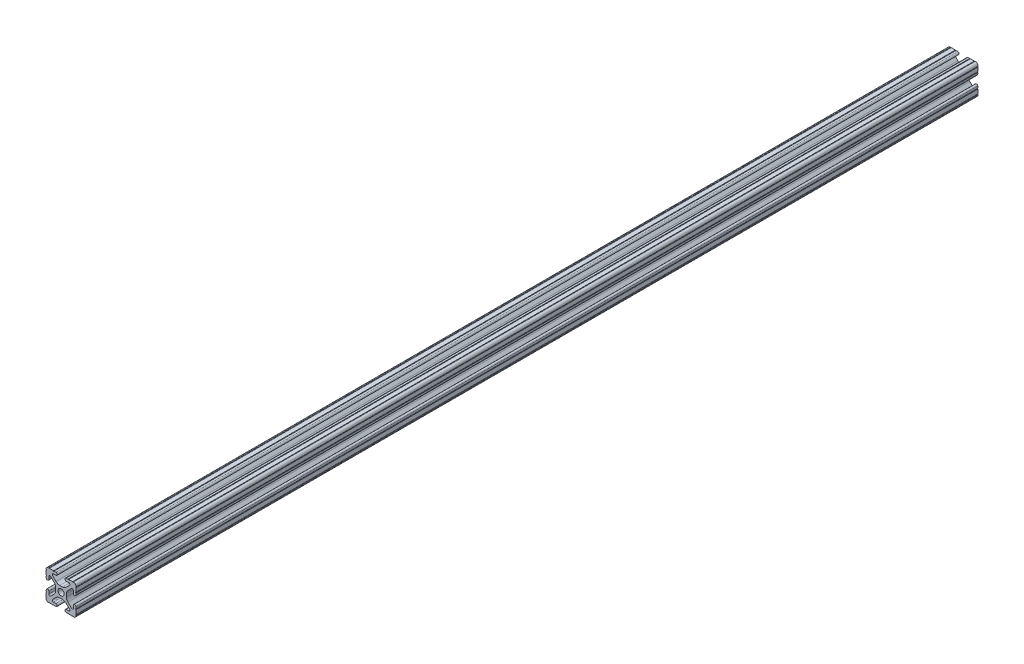
from build123d import *

# Parameters (mm, degrees)
SKETCH3_R      = 2.6035
EXTRUDE1_DEPTH = 380


with BuildPart() as part:
    # Sketch3 → Extrude1 (new body, symmetric)
    with BuildSketch(Plane.XY):
        with BuildLine():
            Line((-1.115277175, 4.5085), (1.115277175, 4.5085))
            ThreePointArc((1.115277175, 4.5085), (2.806584872, 4.844922018), (4.240406305, 5.80297087))
            Line((4.240406305, 5.80297087), (7.148423664, 8.710988229))
            ThreePointArc((7.148423664, 8.710988229), (7.349906316, 9.772227925), (6.436353897, 10.348636575))
            Line((6.436353897, 10.348636575), (4.381960454, 10.276895575))
            ThreePointArc((4.381960454, 10.276895575), (3.239173075, 11.342562046), (4.304839546, 12.485349424))
            Line((4.304839546, 12.485349424), (5.728246175, 12.535055879))
            ThreePointArc((5.728246175, 12.535055879), (6.054756855, 12.230579745), (6.35923299, 12.557090424))
            Line((6.35923299, 12.557090424), (9.782092278, 12.676619304))
            ThreePointArc((9.782092278, 12.676619304), (10.108602958, 12.37214317), (10.413079092, 12.69865385))
            ThreePointArc((10.413079092, 12.69865385), (12.052764565, 12.052764565), (12.69865385, 10.413079092))
            ThreePointArc((12.69865385, 10.413079092), (12.37214317, 10.108602958), (12.676619304, 9.782092278))
            Line((12.676619304, 9.782092278), (12.557090424, 6.35923299))
            ThreePointArc((12.557090424, 6.35923299), (12.230579745, 6.054756855), (12.535055879, 5.728246175))
            Line((12.535055879, 5.728246175), (12.485349424, 4.304839546))
            ThreePointArc((12.485349424, 4.304839546), (11.342562046, 3.239173075), (10.276895575, 4.381960454))
            Line((10.276895575, 4.381960454), (10.348636575, 6.436353897))
            ThreePointArc((10.348636575, 6.436353897), (9.772227925, 7.349906316), (8.710988229, 7.148423664))
            Line((8.710988229, 7.148423664), (5.80297087, 4.240406305))
            ThreePointArc((5.80297087, 4.240406305), (4.844922018, 2.806584872), (4.5085, 1.115277175))
            Line((4.5085, 1.115277175), (4.5085, -1.115277175))
            ThreePointArc((4.5085, -1.115277175), (4.844922018, -2.806584872), (5.80297087, -4.240406305))
            Line((5.80297087, -4.240406305), (8.710988229, -7.148423664))
            ThreePointArc((8.710988229, -7.148423664), (9.772227925, -7.349906316), (10.348636575, -6.436353897))
            Line((10.348636575, -6.436353897), (10.276895575, -4.381960454))
            ThreePointArc((10.276895575, -4.381960454), (11.342562046, -3.239173075), (12.485349424, -4.304839546))
            Line((12.485349424, -4.304839546), (12.535055879, -5.728246175))
            ThreePointArc((12.535055879, -5.728246175), (12.230579745, -6.054756855), (12.557090424, -6.35923299))
            Line((12.557090424, -6.35923299), (12.676619304, -9.782092278))
            ThreePointArc((12.676619304, -9.782092278), (12.37214317, -10.108602958), (12.69865385, -10.413079092))
            ThreePointArc((12.69865385, -10.413079092), (12.052764565, -12.052764565), (10.413079092, -12.69865385))
            ThreePointArc((10.413079092, -12.69865385), (10.108602958, -12.37214317), (9.782092278, -12.676619304))
            Line((9.782092278, -12.676619304), (6.35923299, -12.557090424))
            ThreePointArc((6.35923299, -12.557090424), (6.054756855, -12.230579745), (5.728246175, -12.535055879))
            Line((5.728246175, -12.535055879), (4.304839546, -12.485349424))
            ThreePointArc((4.304839546, -12.485349424), (3.239173075, -11.342562046), (4.381960454, -10.276895575))
            Line((4.381960454, -10.276895575), (6.436353897, -10.348636575))
            ThreePointArc((6.436353897, -10.348636575), (7.349906316, -9.772227925), (7.148423664, -8.710988229))
            Line((7.148423664, -8.710988229), (4.240406305, -5.80297087))
            ThreePointArc((4.240406305, -5.80297087), (2.806584872, -4.844922018), (1.115277175, -4.5085))
            Line((1.115277175, -4.5085), (-1.115277175, -4.5085))
            ThreePointArc((-1.115277175, -4.5085), (-2.806584872, -4.844922018), (-4.240406305, -5.80297087))
            Line((-4.240406305, -5.80297087), (-7.148423664, -8.710988229))
            ThreePointArc((-7.148423664, -8.710988229), (-7.349906316, -9.772227925), (-6.436353897, -10.348636575))
            Line((-6.436353897, -10.348636575), (-4.381960454, -10.276895575))
            ThreePointArc((-4.381960454, -10.276895575), (-3.239173075, -11.342562046), (-4.304839546, -12.485349424))
            Line((-4.304839546, -12.485349424), (-5.728246175, -12.535055879))
            ThreePointArc((-5.728246175, -12.535055879), (-6.054756855, -12.230579745), (-6.35923299, -12.557090424))
            Line((-6.35923299, -12.557090424), (-9.782092278, -12.676619304))
            ThreePointArc((-9.782092278, -12.676619304), (-10.108602958, -12.37214317), (-10.413079092, -12.69865385))
            ThreePointArc((-10.413079092, -12.69865385), (-12.052764565, -12.052764565), (-12.69865385, -10.413079092))
            ThreePointArc((-12.69865385, -10.413079092), (-12.37214317, -10.108602958), (-12.676619304, -9.782092278))
            Line((-12.676619304, -9.782092278), (-12.557090424, -6.35923299))
            ThreePointArc((-12.557090424, -6.35923299), (-12.230579745, -6.054756855), (-12.535055879, -5.728246175))
            Line((-12.535055879, -5.728246175), (-12.485349424, -4.304839546))
            ThreePointArc((-12.485349424, -4.304839546), (-11.342562046, -3.239173075), (-10.276895575, -4.381960454))
            Line((-10.276895575, -4.381960454), (-10.348636575, -6.436353897))
            ThreePointArc((-10.348636575, -6.436353897), (-9.772227925, -7.349906316), (-8.710988229, -7.148423664))
            Line((-8.710988229, -7.148423664), (-5.80297087, -4.240406305))
            ThreePointArc((-5.80297087, -4.240406305), (-4.844922018, -2.806584872), (-4.5085, -1.115277175))
            Line((-4.5085, -1.115277175), (-4.5085, 1.115277175))
            ThreePointArc((-4.5085, 1.115277175), (-4.844922018, 2.806584872), (-5.80297087, 4.240406305))
            Line((-5.80297087, 4.240406305), (-8.710988229, 7.148423664))
            ThreePointArc((-8.710988229, 7.148423664), (-9.772227925, 7.349906316), (-10.348636575, 6.436353897))
            Line((-10.348636575, 6.436353897), (-10.276895575, 4.381960454))
            ThreePointArc((-10.276895575, 4.381960454), (-11.342562046, 3.239173075), (-12.485349424, 4.304839546))
            Line((-12.485349424, 4.304839546), (-12.535055879, 5.728246175))
            ThreePointArc((-12.535055879, 5.728246175), (-12.230579745, 6.054756855), (-12.557090424, 6.35923299))
            Line((-12.557090424, 6.35923299), (-12.676619304, 9.782092278))
            ThreePointArc((-12.676619304, 9.782092278), (-12.37214317, 10.108602958), (-12.69865385, 10.413079092))
            ThreePointArc((-12.69865385, 10.413079092), (-12.052764565, 12.052764565), (-10.413079092, 12.69865385))
            ThreePointArc((-10.413079092, 12.69865385), (-10.108602958, 12.37214317), (-9.782092278, 12.676619304))
            Line((-9.782092278, 12.676619304), (-6.35923299, 12.557090424))
            ThreePointArc((-6.35923299, 12.557090424), (-6.054756855, 12.230579745), (-5.728246175, 12.535055879))
            Line((-5.728246175, 12.535055879), (-4.304839546, 12.485349424))
            ThreePointArc((-4.304839546, 12.485349424), (-3.239173075, 11.342562046), (-4.381960454, 10.276895575))
            Line((-4.381960454, 10.276895575), (-6.436353897, 10.348636575))
            ThreePointArc((-6.436353897, 10.348636575), (-7.349906316, 9.772227925), (-7.148423664, 8.710988229))
            Line((-7.148423664, 8.710988229), (-4.240406305, 5.80297087))
            ThreePointArc((-4.240406305, 5.80297087), (-2.806584872, 4.844922018), (-1.115277175, 4.5085))
        make_face()
        Circle(SKETCH3_R, mode=Mode.SUBTRACT)
    extrude(amount=EXTRUDE1_DEPTH, both=True)


solid = part.part
